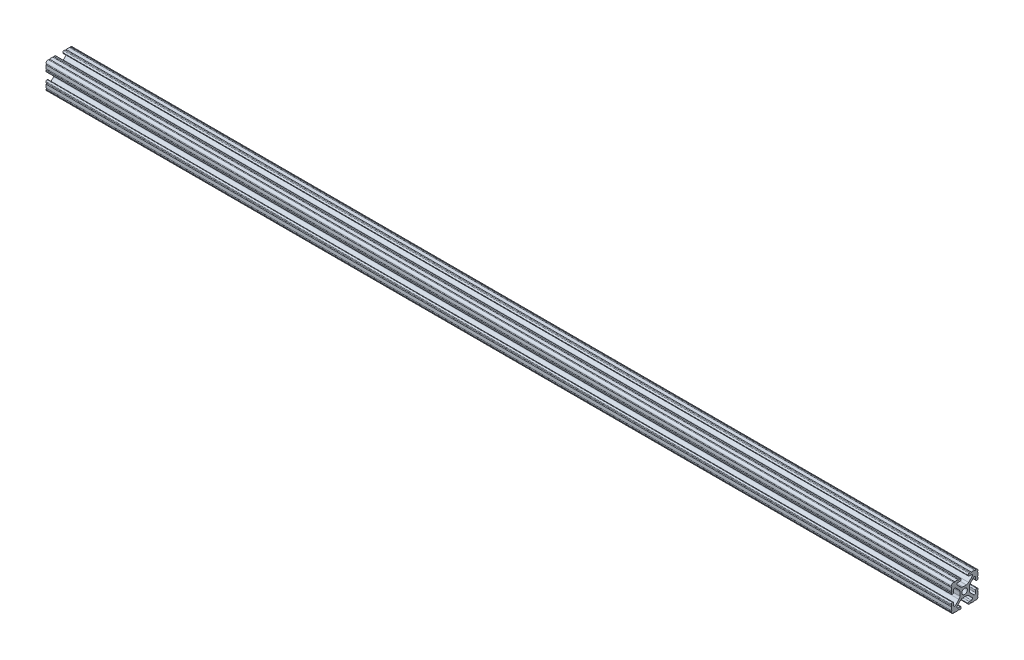
from build123d import *

# Parameters (mm, degrees)
SKETCH16_R                     = 2.6035
EXTRUSION_1010_PROFILE_1_DEPTH = 860


with BuildPart() as part:
    # Sketch16 → Extrusion 1010 PROFILE(1) (new body)
    with BuildSketch(Plane.YZ):
        with BuildLine():
            Line((-1.709253557, -4.4958), (1.709253557, -4.4958))
            ThreePointArc((1.709253557, -4.4958), (2.922935876, -4.736928798), (3.95226937, -5.423689619))
            Line((3.95226937, -5.423689619), (7.179652728, -8.645192207))
            ThreePointArc((7.179652728, -8.645192207), (7.414733441, -9.822812921), (6.41641086, -10.4902))
            Line((6.41641086, -10.4902), (4.28752, -10.4902))
            ThreePointArc((4.28752, -10.4902), (3.545750844, -10.797450844), (3.2385, -11.53922))
            Line((3.2385, -11.53922), (3.2385, -11.65098))
            ThreePointArc((3.2385, -11.65098), (3.545750844, -12.392749156), (4.28752, -12.7))
            Line((4.28752, -12.7), (5.3171344, -12.7))
            ThreePointArc((5.3171344, -12.7), (5.8251344, -12.192), (6.3331344, -12.7))
            Line((6.3331344, -12.7), (9.5504, -12.7))
            ThreePointArc((9.5504, -12.7), (10.058323491, -12.192000006), (10.566399977, -12.699846982))
            ThreePointArc((10.566399977, -12.699846982), (12.082522516, -12.082522516), (12.699846982, -10.566399977))
            ThreePointArc((12.699846982, -10.566399977), (12.192000006, -10.058323491), (12.7, -9.5504))
            Line((12.7, -9.5504), (12.7, -6.3330836))
            ThreePointArc((12.7, -6.3330836), (12.192, -5.8250836), (12.7, -5.3170836))
            Line((12.7, -5.3170836), (12.7, -4.287470133))
            ThreePointArc((12.7, -4.287470133), (12.392749156, -3.545700977), (11.65098, -3.238450133))
            Line((11.65098, -3.238450133), (11.53922, -3.238450133))
            ThreePointArc((11.53922, -3.238450133), (10.797450844, -3.545700977), (10.4902, -4.287470133))
            Line((10.4902, -4.287470133), (10.4902, -6.402089023))
            ThreePointArc((10.4902, -6.402089023), (9.856394933, -7.351113629), (8.736962546, -7.129240479))
            Line((8.736962546, -7.129240479), (5.440484187, -3.838768792))
            ThreePointArc((5.440484187, -3.838768792), (4.75073678, -2.808015636), (4.5085, -1.591658411))
            Line((4.5085, -1.591658411), (4.5085, 1.591658411))
            ThreePointArc((4.5085, 1.591658411), (4.75073678, 2.808015636), (5.440484187, 3.838768792))
            Line((5.440484187, 3.838768792), (8.736962546, 7.129240479))
            ThreePointArc((8.736962546, 7.129240479), (9.856394933, 7.351113629), (10.4902, 6.402089023))
            Line((10.4902, 6.402089023), (10.4902, 4.287470133))
            ThreePointArc((10.4902, 4.287470133), (10.797450844, 3.545700977), (11.53922, 3.238450133))
            Line((11.53922, 3.238450133), (11.65098, 3.238450133))
            ThreePointArc((11.65098, 3.238450133), (12.392749156, 3.545700977), (12.7, 4.287470133))
            Line((12.7, 4.287470133), (12.7, 5.3171344))
            ThreePointArc((12.7, 5.3171344), (12.192, 5.8251344), (12.7, 6.3331344))
            Line((12.7, 6.3331344), (12.7, 9.5504))
            ThreePointArc((12.7, 9.5504), (12.192000006, 10.058323491), (12.699846982, 10.566399977))
            ThreePointArc((12.699846982, 10.566399977), (12.082522516, 12.082522516), (10.566399977, 12.699846982))
            ThreePointArc((10.566399977, 12.699846982), (10.058323491, 12.192000006), (9.5504, 12.7))
            Line((9.5504, 12.7), (6.3330836, 12.7))
            ThreePointArc((6.3330836, 12.7), (5.8250836, 12.192), (5.3170836, 12.7))
            Line((5.3170836, 12.7), (4.2874692, 12.7))
            ThreePointArc((4.2874692, 12.7), (3.545700044, 12.392749156), (3.2384492, 11.65098))
            Line((3.2384492, 11.65098), (3.2384492, 11.53922))
            ThreePointArc((3.2384492, 11.53922), (3.545700044, 10.797450844), (4.2874692, 10.4902))
            Line((4.2874692, 10.4902), (6.476774195, 10.4902))
            ThreePointArc((6.476774195, 10.4902), (7.43216212, 9.851515102), (7.207191475, 8.724540082))
            Line((7.207191475, 8.724540082), (3.900315394, 5.423689619))
            ThreePointArc((3.900315394, 5.423689619), (2.8709819, 4.736928798), (1.657299581, 4.4958))
            Line((1.657299581, 4.4958), (-1.657299581, 4.4958))
            ThreePointArc((-1.657299581, 4.4958), (-2.8709819, 4.736928798), (-3.900315394, 5.423689619))
            Line((-3.900315394, 5.423689619), (-7.207191475, 8.724540082))
            ThreePointArc((-7.207191475, 8.724540082), (-7.43216212, 9.851515102), (-6.476774195, 10.4902))
            Line((-6.476774195, 10.4902), (-4.2874692, 10.4902))
            ThreePointArc((-4.2874692, 10.4902), (-3.545700044, 10.797450844), (-3.2384492, 11.53922))
            Line((-3.2384492, 11.53922), (-3.2384492, 11.65098))
            ThreePointArc((-3.2384492, 11.65098), (-3.545700044, 12.392749156), (-4.2874692, 12.7))
            Line((-4.2874692, 12.7), (-5.3170836, 12.7))
            ThreePointArc((-5.3170836, 12.7), (-5.8250836, 12.192), (-6.3330836, 12.7))
            Line((-6.3330836, 12.7), (-9.5504, 12.7))
            ThreePointArc((-9.5504, 12.7), (-10.058323491, 12.192000006), (-10.566399977, 12.699846982))
            ThreePointArc((-10.566399977, 12.699846982), (-12.082522516, 12.082522516), (-12.699846982, 10.566399977))
            ThreePointArc((-12.699846982, 10.566399977), (-12.192000006, 10.058323491), (-12.7, 9.5504))
            Line((-12.7, 9.5504), (-12.7, 6.3331344))
            ThreePointArc((-12.7, 6.3331344), (-12.192, 5.8251344), (-12.7, 5.3171344))
            Line((-12.7, 5.3171344), (-12.7, 4.287470133))
            ThreePointArc((-12.7, 4.287470133), (-12.392749156, 3.545700977), (-11.65098, 3.238450133))
            Line((-11.65098, 3.238450133), (-11.53922, 3.238450133))
            ThreePointArc((-11.53922, 3.238450133), (-10.797450844, 3.545700977), (-10.4902, 4.287470133))
            Line((-10.4902, 4.287470133), (-10.4902, 6.402089023))
            ThreePointArc((-10.4902, 6.402089023), (-9.856394933, 7.351113629), (-8.736962546, 7.129240479))
            Line((-8.736962546, 7.129240479), (-5.440484187, 3.838768792))
            ThreePointArc((-5.440484187, 3.838768792), (-4.75073678, 2.808015636), (-4.5085, 1.591658411))
            Line((-4.5085, 1.591658411), (-4.5085, -1.591658411))
            ThreePointArc((-4.5085, -1.591658411), (-4.75073678, -2.808015636), (-5.440484187, -3.838768792))
            Line((-5.440484187, -3.838768792), (-8.736962546, -7.129240479))
            ThreePointArc((-8.736962546, -7.129240479), (-9.856394933, -7.351113629), (-10.4902, -6.402089023))
            Line((-10.4902, -6.402089023), (-10.4902, -4.287470133))
            ThreePointArc((-10.4902, -4.287470133), (-10.797450844, -3.545700977), (-11.53922, -3.238450133))
            Line((-11.53922, -3.238450133), (-11.65098, -3.238450133))
            ThreePointArc((-11.65098, -3.238450133), (-12.392749156, -3.545700977), (-12.7, -4.287470133))
            Line((-12.7, -4.287470133), (-12.7, -5.3170836))
            ThreePointArc((-12.7, -5.3170836), (-12.192, -5.8250836), (-12.7, -6.3330836))
            Line((-12.7, -6.3330836), (-12.7, -9.5504))
            ThreePointArc((-12.7, -9.5504), (-12.192000006, -10.058323491), (-12.699846982, -10.566399977))
            ThreePointArc((-12.699846982, -10.566399977), (-12.082522516, -12.082522516), (-10.566399977, -12.699846982))
            ThreePointArc((-10.566399977, -12.699846982), (-10.058323491, -12.192000006), (-9.5504, -12.7))
            Line((-9.5504, -12.7), (-6.3331344, -12.7))
            ThreePointArc((-6.3331344, -12.7), (-5.8251344, -12.192), (-5.3171344, -12.7))
            Line((-5.3171344, -12.7), (-4.28752, -12.7))
            ThreePointArc((-4.28752, -12.7), (-3.545750844, -12.392749156), (-3.2385, -11.65098))
            Line((-3.2385, -11.65098), (-3.2385, -11.53922))
            ThreePointArc((-3.2385, -11.53922), (-3.545750844, -10.797450844), (-4.28752, -10.4902))
            Line((-4.28752, -10.4902), (-6.41641086, -10.4902))
            ThreePointArc((-6.41641086, -10.4902), (-7.414733441, -9.822812921), (-7.179652728, -8.645192207))
            Line((-7.179652728, -8.645192207), (-3.95226937, -5.423689619))
            ThreePointArc((-3.95226937, -5.423689619), (-2.922935876, -4.736928798), (-1.709253557, -4.4958))
        make_face()
        Circle(SKETCH16_R, mode=Mode.SUBTRACT)
    extrude(amount=EXTRUSION_1010_PROFILE_1_DEPTH)


solid = part.part
